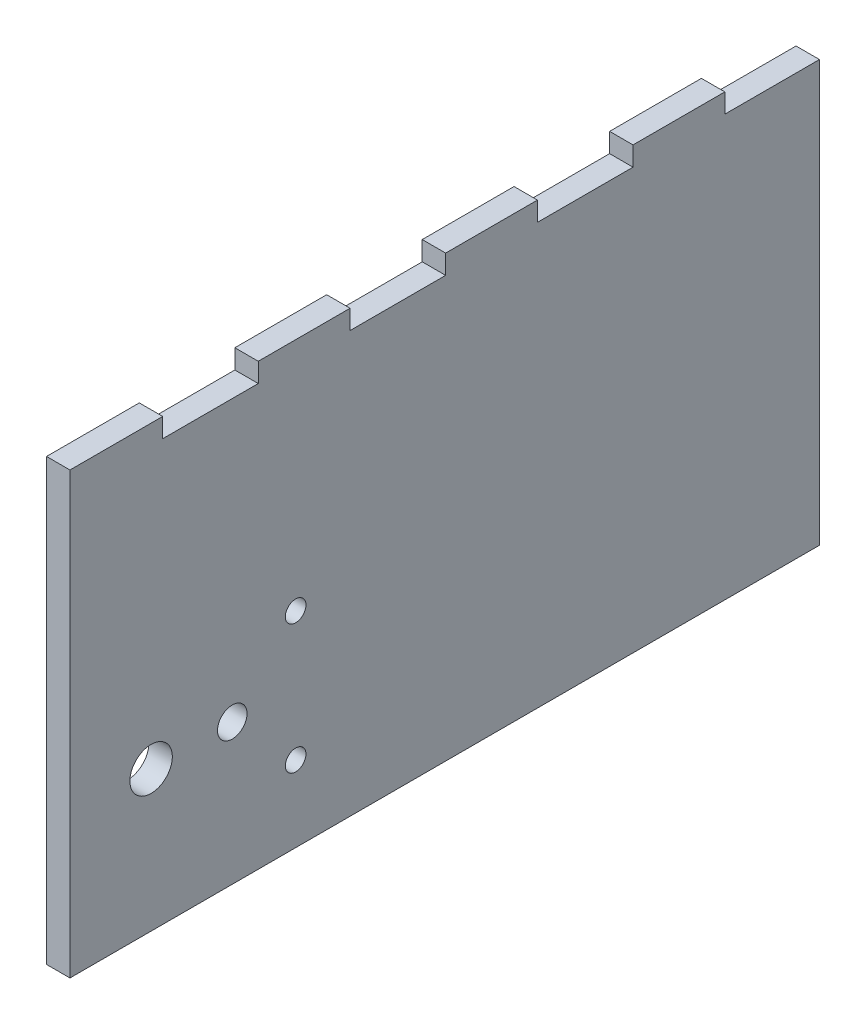
from build123d import *

# Parameters (mm, degrees)
BOSS_EXTRUDE1_DEPTH = 3.175
CUT_EXTRUDE1_REACH  = 5.175
SKETCH2_R           = 1.4
SKETCH2_R_2         = 2
SKETCH2_R_3         = 2.876999961
CUT_EXTRUDE2_DEPTH  = 4.175


with BuildPart() as part:
    # Sketch1 → Boss-Extrude1 (new body)
    with BuildSketch(Plane(origin=(0, 0, 0), x_dir=(0, 0, -1), z_dir=(1, 0, 0))):
        Polygon((0, 0), (0, 59.6392), (12.7, 59.6392), (12.7, 57.15), (25.4, 57.15), (25.4, 59.6392), (38.1, 59.6392), (38.1, 57.15), (50.8, 57.15), (50.8, 59.6392), (63.5, 59.6392), (63.5, 57.15), (76.2, 57.15), (76.2, 59.6392), (88.9, 59.6392), (88.9, 57.15), (101.6, 57.15), (101.6, 0), align=None)
    extrude(amount=BOSS_EXTRUDE1_DEPTH)

    # Sketch2 → Cut-Extrude1 (cut, up to next)
    with BuildSketch(Plane(origin=(3.175, 0, 0), x_dir=(0, 0, -1), z_dir=(1, 0, 0)), mode=Mode.PRIVATE) as cut_extrude1_sk1:
        with Locations((30.59102, 10.3)):
            Circle(SKETCH2_R)
    cut_extrude1_tool1 = extrude(cut_extrude1_sk1.sketch, amount=-CUT_EXTRUDE1_REACH, mode=Mode.PRIVATE) & part.part
    add(cut_extrude1_tool1.solids().sort_by_distance((3.175, 10.3, -30.59102))[0], mode=Mode.SUBTRACT)
    # Sketch2 → Cut-Extrude1 (cut, up to next)
    with BuildSketch(Plane(origin=(3.175, 0, 0), x_dir=(0, 0, -1), z_dir=(1, 0, 0)), mode=Mode.PRIVATE) as cut_extrude1_sk2:
        with Locations((30.59102, 27.8)):
            Circle(SKETCH2_R)
    cut_extrude1_tool2 = extrude(cut_extrude1_sk2.sketch, amount=-CUT_EXTRUDE1_REACH, mode=Mode.PRIVATE) & part.part
    add(cut_extrude1_tool2.solids().sort_by_distance((3.175, 27.8, -30.59102))[0], mode=Mode.SUBTRACT)
    # Sketch2 → Cut-Extrude1 (cut, up to next)
    with BuildSketch(Plane(origin=(3.175, 0, 0), x_dir=(0, 0, -1), z_dir=(1, 0, 0)), mode=Mode.PRIVATE) as cut_extrude1_sk3:
        with Locations((22.0000034, 19.05)):
            Circle(SKETCH2_R_2)
    cut_extrude1_tool3 = extrude(cut_extrude1_sk3.sketch, amount=-CUT_EXTRUDE1_REACH, mode=Mode.PRIVATE) & part.part
    add(cut_extrude1_tool3.solids().sort_by_distance((3.175, 19.05, -22.000003))[0], mode=Mode.SUBTRACT)
    # Sketch2 → Cut-Extrude1 (cut, up to next)
    with BuildSketch(Plane(origin=(3.175, 0, 0), x_dir=(0, 0, -1), z_dir=(1, 0, 0)), mode=Mode.PRIVATE) as cut_extrude1_sk4:
        with Locations((11, 19.05)):
            Circle(SKETCH2_R_3)
    cut_extrude1_tool4 = extrude(cut_extrude1_sk4.sketch, amount=-CUT_EXTRUDE1_REACH, mode=Mode.PRIVATE) & part.part
    add(cut_extrude1_tool4.solids().sort_by_distance((3.175, 19.05, -11))[0], mode=Mode.SUBTRACT)

    # Sketch3 → Cut-Extrude2 (cut, through all)
    with BuildSketch(Plane(origin=(3.175, 0, 0), x_dir=(0, 0, -1), z_dir=(1, 0, 0))):
        Polygon((12.7, 57.15), (12.7, 59.6392), (12.573, 59.6392), (12.573, 57.023), (25.527, 57.023), (25.527, 59.6392), (25.4, 59.6392), (25.4, 57.15), align=None)
        Polygon((38.1, 59.6392), (37.973, 59.6392), (37.973, 57.023), (50.927, 57.023), (50.927, 59.6392), (50.8, 59.6392), (50.8, 57.15), (38.1, 57.15), align=None)
        Polygon((63.5, 59.6392), (63.373, 59.6392), (63.373, 57.023), (76.327, 57.023), (76.327, 59.6392), (76.2, 59.6392), (76.2, 57.15), (63.5, 57.15), align=None)
        Polygon((88.9, 59.6392), (88.773, 59.6392), (88.773, 57.023), (101.6, 57.023), (101.6, 57.15), (88.9, 57.15), align=None)
    extrude(amount=-CUT_EXTRUDE2_DEPTH, mode=Mode.SUBTRACT)


solid = part.part
